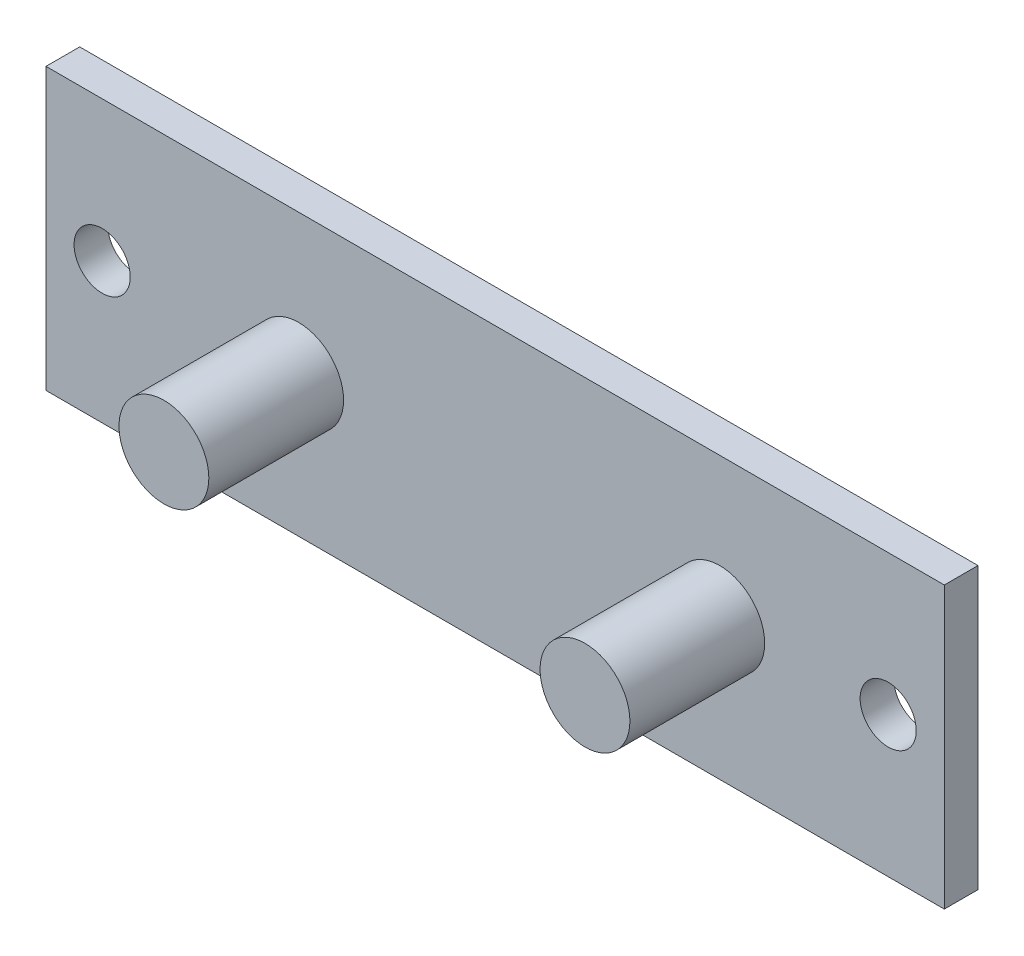
from build123d import *

# Parameters (mm, degrees)
SKETCH1_W           = 80
SKETCH1_H           = 25
BOSS_EXTRUDE1_DEPTH = 3
SKETCH2_R           = 4
BOSS_EXTRUDE2_DEPTH = 12
SKETCH3_R           = 2.5
CUT_EXTRUDE1_DEPTH  = 8


with BuildPart() as part:
    # Sketch1 → Boss-Extrude1 (new body)
    with BuildSketch(Plane.XY):
        with Locations((-40, 12.5)):
            Rectangle(SKETCH1_W, SKETCH1_H)
    extrude(amount=BOSS_EXTRUDE1_DEPTH)

    # Sketch2 → Boss-Extrude2 (add)
    with BuildSketch(Plane.XY.offset(3)):
        with Locations((-57.5, 12.5)):
            Circle(SKETCH2_R)
        with Locations((-20, 12.5)):
            Circle(SKETCH2_R)
    extrude(amount=BOSS_EXTRUDE2_DEPTH)

    # Sketch3 → Cut-Extrude1 (cut)
    with BuildSketch(Plane.XY.offset(3)):
        with Locations((-75, 12.5)):
            Circle(SKETCH3_R)
        with Locations((-5, 12.5)):
            Circle(SKETCH3_R)
    extrude(amount=-CUT_EXTRUDE1_DEPTH, mode=Mode.SUBTRACT)


solid = part.part
